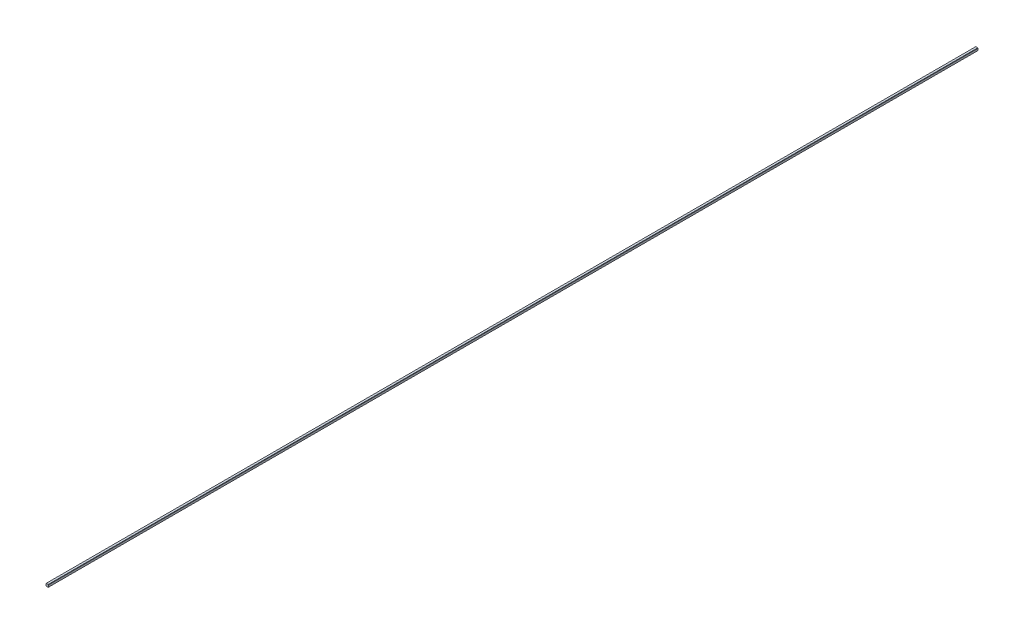
from build123d import *

# Parameters (mm, degrees)
BOSS_EXTRUDE1_DEPTH = 185


with BuildPart() as part:
    # Sketch1 → Boss-Extrude1 (new body)
    with BuildSketch(Plane.XY):
        Polygon((-0.2, 0.25), (-0.25, 0.2), (-0.25, -0.2), (-0.2, -0.25), (0.2, -0.25), (0.25, -0.2), (0.25, 0.2), (0.2, 0.25), align=None)
    extrude(amount=BOSS_EXTRUDE1_DEPTH)


solid = part.part
